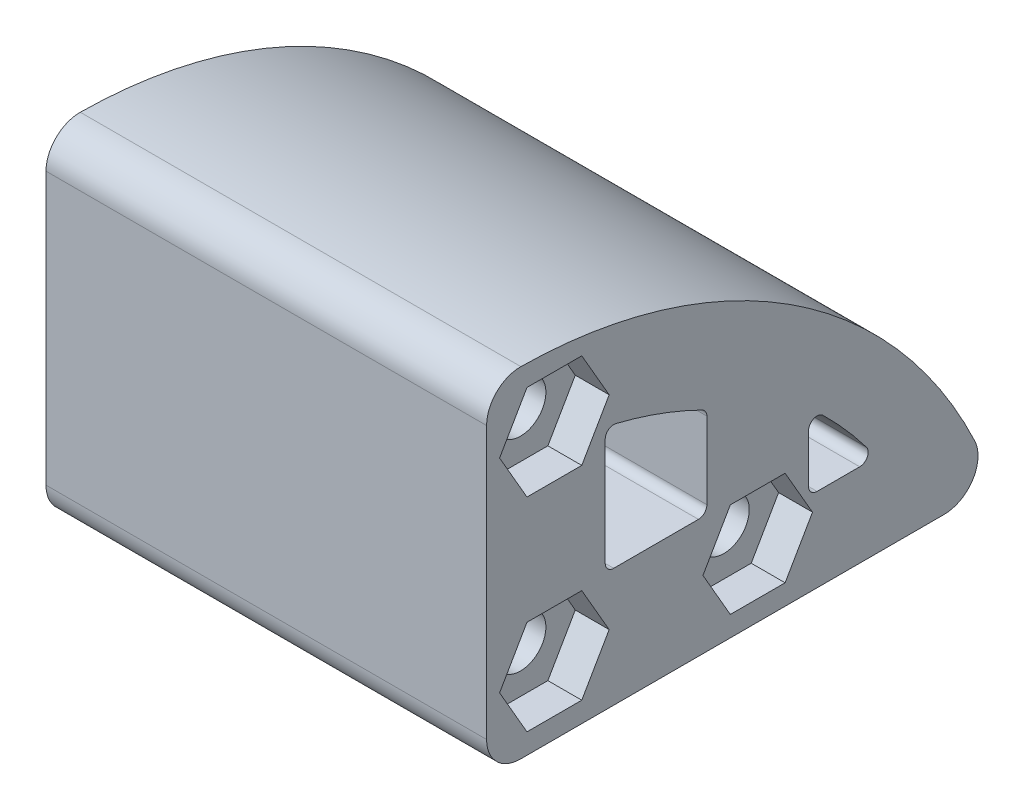
from build123d import *

# Parameters (mm, degrees)
SKETCH1_R           = 1.5
BOSS_EXTRUDE1_DEPTH = 26
CUT_EXTRUDE1_DEPTH  = 2
CUT_EXTRUDE2_START  = 26
CUT_EXTRUDE2_DEPTH  = 2


with BuildPart() as part:
    # Sketch1 → Boss-Extrude1 (new body)
    with BuildSketch(Plane(origin=(0, 0, 0), x_dir=(0, 0, -1), z_dir=(1, 0, 0))):
        with BuildLine():
            Line((-4, 14.045215535), (-4, -2))
            ThreePointArc((-4, -2), (-3.414213562, -3.414213562), (-2, -4))
            Line((-2, -4), (23, -4))
            ThreePointArc((23, -4), (24.68931411, -3.070615635), (24.808606098, -1.146217837))
            ThreePointArc((24.808606098, -1.146217837), (13.883506503, 11.294438637), (-1.977108188, 16.045084522))
            ThreePointArc((-1.977108188, 16.045084522), (-3.406096792, 15.467499547), (-4, 14.045215535))
        make_face()
        Circle(SKETCH1_R, mode=Mode.SUBTRACT)
        with Locations((0, 12)):
            Circle(SKETCH1_R, mode=Mode.SUBTRACT)
        with Locations((12, 0)):
            Circle(SKETCH1_R, mode=Mode.SUBTRACT)
        with BuildLine():
            Line((3, 9.845620053), (3, 3.5))
            ThreePointArc((3, 3.5), (3.146446609, 3.146446609), (3.5, 3))
            Line((3.5, 3), (8.5, 3))
            ThreePointArc((8.5, 3), (8.853553391, 3.146446609), (9, 3.5))
            Line((9, 3.5), (9, 8.028111937))
            ThreePointArc((9, 8.028111937), (8.92450743, 8.292296422), (8.720826232, 8.476705043))
            ThreePointArc((8.720826232, 8.476705043), (6.220295037, 9.542901904), (3.618785416, 10.331305162))
            ThreePointArc((3.618785416, 10.331305162), (3.191287114, 10.238934627), (3, 9.845620053))
        make_face(mode=Mode.SUBTRACT)
        with BuildLine():
            Line((15, 4.286575508), (15, 1.427805862))
            ThreePointArc((15, 1.427805862), (15.146446609, 1.074252472), (15.5, 0.927805862))
            Line((15.5, 0.927805862), (18.01869702, 0.927805862))
            ThreePointArc((18.01869702, 0.927805862), (18.466352985, 1.205086001), (18.417504517, 1.729389316))
            ThreePointArc((18.417504517, 1.729389316), (17.187978253, 3.234831626), (15.849421282, 4.644213269))
            ThreePointArc((15.849421282, 4.644213269), (15.305977631, 4.747395777), (15, 4.286575508))
        make_face(mode=Mode.SUBTRACT)
    extrude(amount=BOSS_EXTRUDE1_DEPTH)

    # Sketch2 → Cut-Extrude1 (cut)
    with BuildSketch(Plane(origin=(0, 0, 0), x_dir=(0, 0, -1), z_dir=(1, 0, 0))):
        Polygon((-1.616580754, 9.2), (1.616580754, 9.2), (3.233161507, 12), (1.616580754, 14.8), (-1.616580754, 14.8), (-3.233161507, 12), align=None)
        Polygon((1.616580754, 2.8), (-1.616580754, 2.8), (-3.233161507, 0), (-1.616580754, -2.8), (1.616580754, -2.8), (3.233161507, 0), align=None)
        Polygon((15.233161507, 0), (13.616580754, 2.8), (10.383419246, 2.8), (8.766838493, 0), (10.383419246, -2.8), (13.616580754, -2.8), align=None)
    extrude(amount=CUT_EXTRUDE1_DEPTH, mode=Mode.SUBTRACT)

    # Sketch2_3 → Cut-Extrude2 (cut)
    with BuildSketch(Plane(origin=(0, 0, 0), x_dir=(0, 0, -1), z_dir=(1, 0, 0)).offset(CUT_EXTRUDE2_START)):
        Polygon((-1.616580754, 9.2), (1.616580754, 9.2), (3.233161507, 12), (1.616580754, 14.8), (-1.616580754, 14.8), (-3.233161507, 12), align=None)
        Polygon((1.616580754, 2.8), (-1.616580754, 2.8), (-3.233161507, 0), (-1.616580754, -2.8), (1.616580754, -2.8), (3.233161507, 0), align=None)
        Polygon((15.233161507, 0), (13.616580754, 2.8), (10.383419246, 2.8), (8.766838493, 0), (10.383419246, -2.8), (13.616580754, -2.8), align=None)
    extrude(amount=-CUT_EXTRUDE2_DEPTH, mode=Mode.SUBTRACT)


solid = part.part
